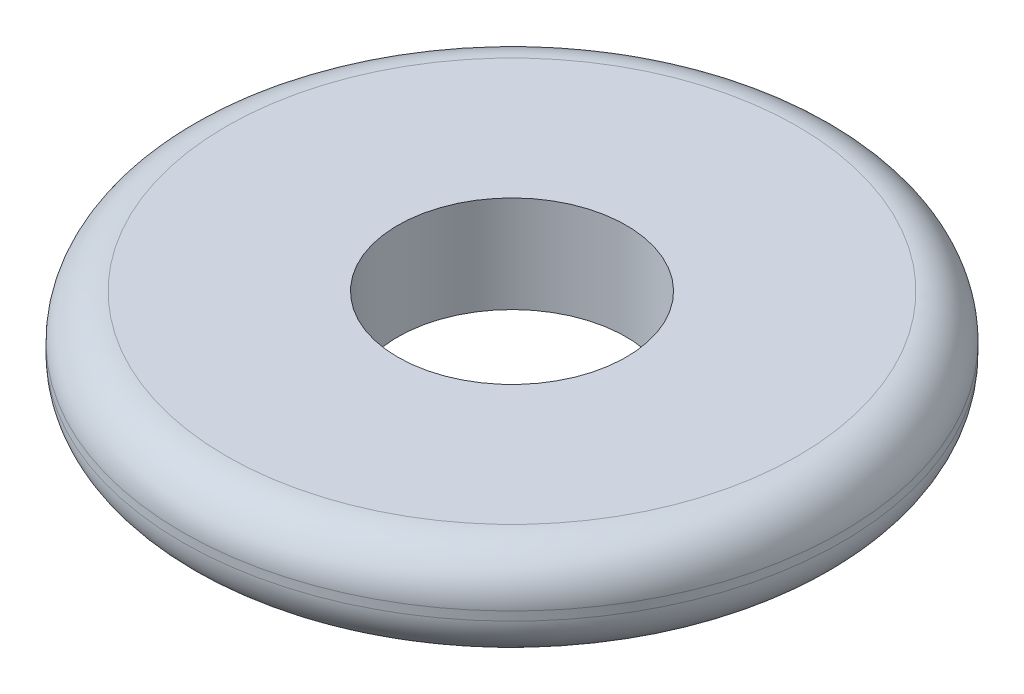
from build123d import *

# Parameters (mm, degrees)
SKETCH1_R           = 3.75
BOSS_EXTRUDE1_DEPTH = 1.1
SKETCH2_R           = 1.3
CUT_EXTRUDE1_DEPTH  = 2.1
FILLET1_R           = 0.5


with BuildPart() as part:
    # Sketch1 → Boss-Extrude1 (new body)
    with BuildSketch(Plane(origin=(0, 0, 0), x_dir=(1, 0, 0), z_dir=(0, 1, 0))):
        Circle(SKETCH1_R)
    extrude(amount=BOSS_EXTRUDE1_DEPTH)

    # Sketch2 → Cut-Extrude1 (cut, through all)
    with BuildSketch(Plane(origin=(0, 1.1, 0), x_dir=(1, 0, 0), z_dir=(0, 1, 0))):
        Circle(SKETCH2_R)
    extrude(amount=-CUT_EXTRUDE1_DEPTH, mode=Mode.SUBTRACT)

    # Fillet1
    fillet1_edges = [part.edges().sort_by_distance(p)[0] for p in [
        (-3.75, 0, 0),
        (-3.75, 1.1, 0),
    ]]
    fillet(fillet1_edges, radius=FILLET1_R)


solid = part.part
